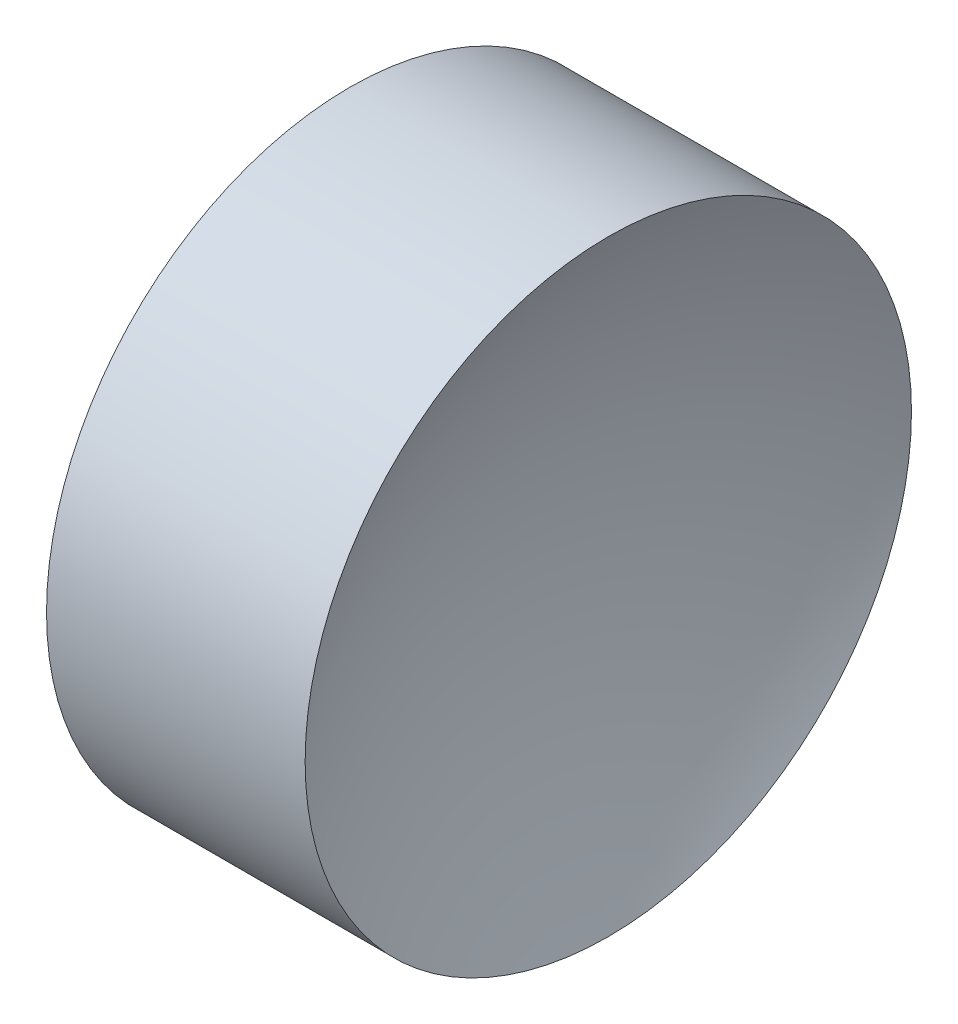
from build123d import *


with BuildPart() as part:
    # 草图1 → 旋转1 (revolve)
    with BuildSketch(Plane.XY):
        with BuildLine():
            Line((46.845221984, 26.089041149), (49.245221984, 26.089041149))
            ThreePointArc((49.245221984, 26.089041149), (49.627502349, 29.352392068), (50.75364397, 32.439041149))
            Line((50.75364397, 32.439041149), (48.045221984, 32.439041149))
            Line((48.045221984, 32.439041149), (45.336799998, 32.439041149))
            ThreePointArc((45.336799998, 32.439041149), (46.462941619, 29.352392068), (46.845221984, 26.089041149))
        make_face()
    revolve(axis=Axis((42.449861114, 26.089041149, 0), (1, 0, 0)))


solid = part.part
